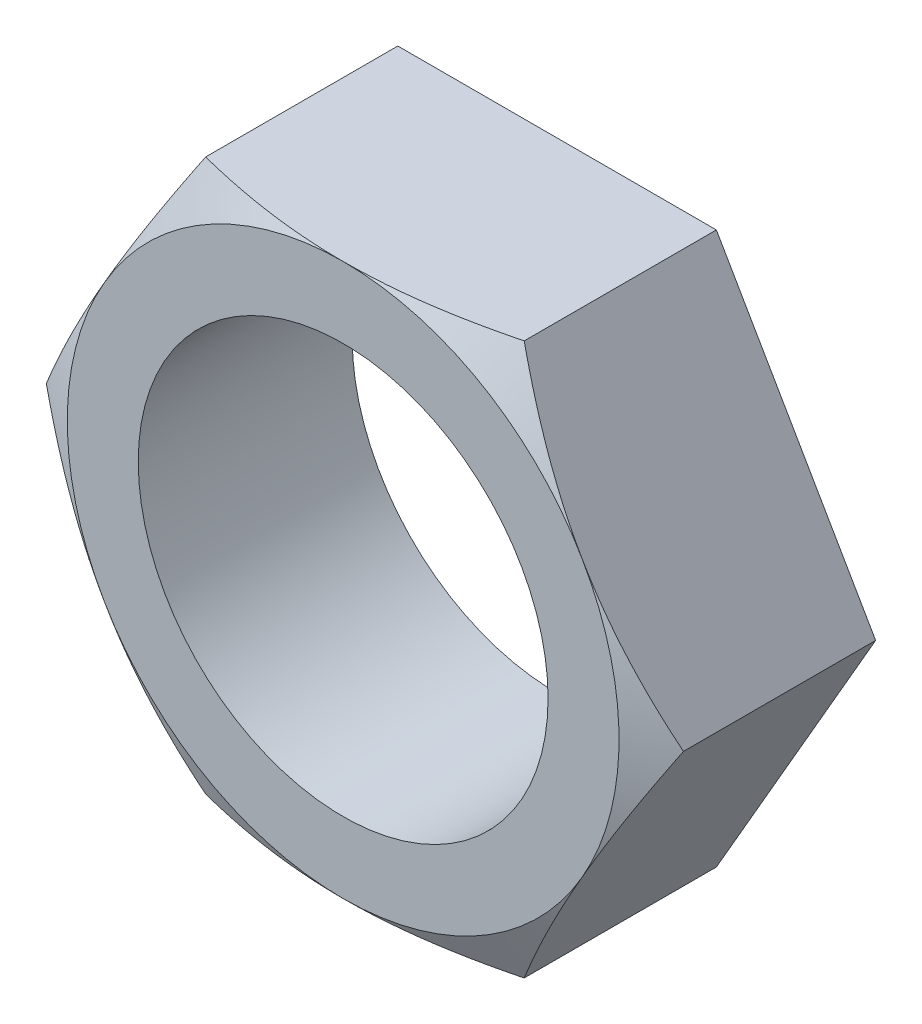
from build123d import *

# Parameters (mm, degrees)
SKETCH1_R           = 22.8092
BOSS_EXTRUDE1_DEPTH = 23.8125
SKETCH2_OUTSIDE_W   = 102.245
SKETCH2_OUTSIDE_H   = 92.744
SKETCH2_OUTSIDE_R   = 30.707875178
CUT_EXTRUDE1_DEPTH  = 2.54
CUT_EXTRUDE1_TAPER  = 63


with BuildPart() as part:
    # Sketch1 → Boss-Extrude1 (new body)
    with BuildSketch(Plane.XY):
        Polygon((129.341403954, 1350.513952992), (147.070603954, 1319.806077815), (182.529003954, 1319.806077815), (200.258203954, 1350.513952992), (182.529003954, 1381.22182817), (147.070603954, 1381.22182817), align=None)
        with Locations((164.799803954, 1350.513952992)):
            Circle(SKETCH1_R, mode=Mode.SUBTRACT)
    extrude(amount=BOSS_EXTRUDE1_DEPTH)

    # Sketch2 outside → Cut-Extrude1 (cut)
    with BuildSketch(Plane.XY.offset(23.8125)):
        with Locations((164.7995, 1350.514)):
            Rectangle(SKETCH2_OUTSIDE_W, SKETCH2_OUTSIDE_H)
        with Locations((164.799803954, 1350.513952992)):
            Circle(SKETCH2_OUTSIDE_R, mode=Mode.SUBTRACT)
    extrude(amount=-CUT_EXTRUDE1_DEPTH, taper=CUT_EXTRUDE1_TAPER, mode=Mode.SUBTRACT)


solid = part.part
